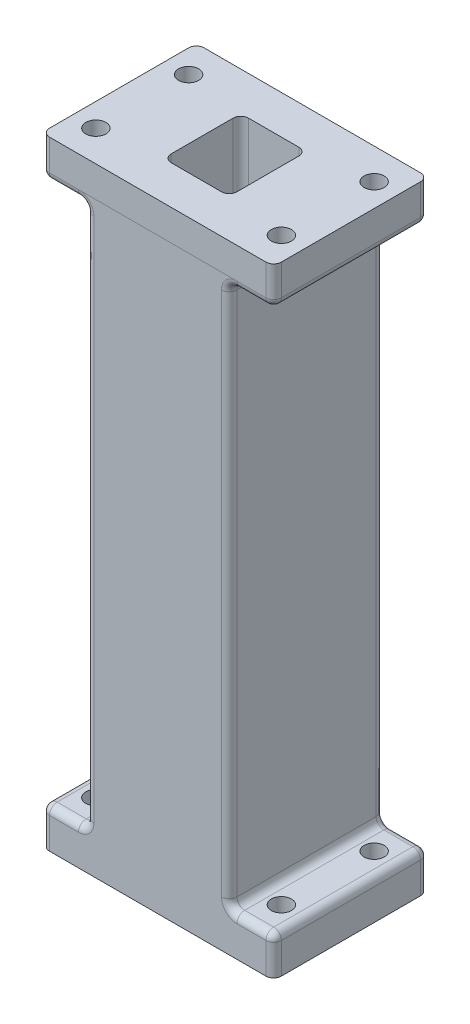
from build123d import *

# Parameters (mm, degrees)
SKETCH1_W           = 30
SKETCH1_H           = 20
SKETCH1_R           = 1.3
BOSS_EXTRUDE1_DEPTH = 5
SKETCH2_W           = 18.5
SKETCH2_H           = 20
BOSS_EXTRUDE2_DEPTH = 70
FILLET1_R           = 1
SKETCH12_W          = 8.5
SKETCH12_H          = 10
CUT_EXTRUDE1_DEPTH  = 83.006097334
FILLET2_R           = 1


with BuildPart() as part:
    # Sketch1 → Boss-Extrude1 (new body)
    with BuildSketch(Plane(origin=(0, 0, 0), x_dir=(1, 0, 0), z_dir=(0, 1, 0))):
        Rectangle(SKETCH1_W, SKETCH1_H)
        with Locations((-12, 6)):
            Circle(SKETCH1_R, mode=Mode.SUBTRACT)
        with Locations((12, 6)):
            Circle(SKETCH1_R, mode=Mode.SUBTRACT)
        with Locations((12, -6)):
            Circle(SKETCH1_R, mode=Mode.SUBTRACT)
        with Locations((-12, -6)):
            Circle(SKETCH1_R, mode=Mode.SUBTRACT)
    boss_extrude1 = extrude(amount=BOSS_EXTRUDE1_DEPTH)

    # Sketch2 → Boss-Extrude2 (add)
    with BuildSketch(Plane(origin=(0, 5, 0), x_dir=(1, 0, 0), z_dir=(0, 1, 0))):
        Rectangle(SKETCH2_W, SKETCH2_H)
    extrude(amount=BOSS_EXTRUDE2_DEPTH)

    # Mirror1: Boss-Extrude1 across plane
    add(boss_extrude1.mirror(Plane.ZX.offset(40)))

    # Fillet1
    fillet1_edges = [part.edges().sort_by_distance(p)[0] for p in [
        (12.125, 5, -10),
        (12.125, 5, 10),
        (-12.125, 5, -10),
        (-12.125, 5, 10),
        (-9.25, 75, 0),
        (9.25, 75, 0),
        (12.125, 75, 10),
        (15, 75, 0),
        (12.125, 75, -10),
        (9.25, 40, -10),
        (15, 5, 0),
        (9.25, 40, 10),
        (9.25, 5, 0),
        (-15, 5, 0),
        (-9.25, 5, 0),
        (-9.25, 40, 10),
        (-9.25, 40, -10),
        (-12.125, 75, -10),
        (-15, 75, 0),
        (-12.125, 75, 10),
        (15, 2.5, -10),
        (15, 2.5, 10),
        (-15, 2.5, 10),
        (-15, 2.5, -10),
        (-15, 77.5, -10),
        (-15, 77.5, 10),
        (15, 77.5, -10),
        (15, 77.5, 10),
    ]]
    fillet(fillet1_edges, radius=FILLET1_R)

    # Sketch12 → Cut-Extrude1 (cut, through all)
    with BuildSketch(Plane(origin=(0, 80, 0), x_dir=(1, 0, 0), z_dir=(0, 1, 0))):
        Rectangle(SKETCH12_W, SKETCH12_H)
    extrude(amount=-CUT_EXTRUDE1_DEPTH, mode=Mode.SUBTRACT)

    # Fillet2
    fillet2_edges = [part.edges().sort_by_distance(p)[0] for p in [
        (4.25, 40, 5),
        (-4.25, 40, 5),
        (4.25, 40, -5),
        (-4.25, 40, -5),
    ]]
    fillet(fillet2_edges, radius=FILLET2_R)


solid = part.part
